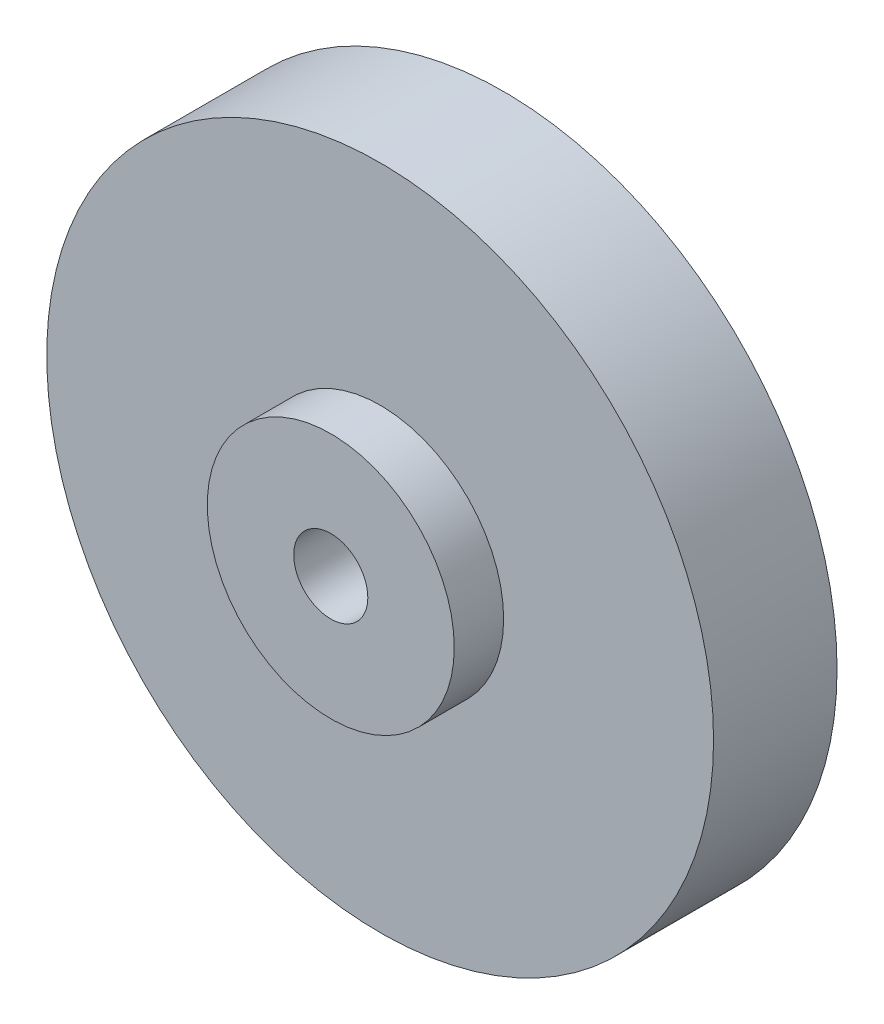
from build123d import *

# Parameters (mm, degrees)
SKETCH1_R           = 13.5
BOSS_EXTRUDE1_DEPTH = 5
SKETCH2_R           = 5
BOSS_EXTRUDE2_DEPTH = 2
SKETCH3_R           = 1.5
CUT_EXTRUDE1_DEPTH  = 8
CHAMFER1_SIZE       = 2


with BuildPart() as part:
    # Sketch1 → Boss-Extrude1 (new body)
    with BuildSketch(Plane.XY):
        Circle(SKETCH1_R)
    extrude(amount=BOSS_EXTRUDE1_DEPTH)

    # Sketch2 → Boss-Extrude2 (add)
    with BuildSketch(Plane.XY.offset(5)):
        Circle(SKETCH2_R)
    extrude(amount=BOSS_EXTRUDE2_DEPTH)

    # Sketch3 → Cut-Extrude1 (cut, through all)
    with BuildSketch(Plane.XY.offset(7)):
        Circle(SKETCH3_R)
    extrude(amount=-CUT_EXTRUDE1_DEPTH, mode=Mode.SUBTRACT)

    # Chamfer1
    chamfer1_edges = [part.edges().sort_by_distance(p)[0] for p in [
        (-1.5, 0, 0),
    ]]
    chamfer(chamfer1_edges, length=CHAMFER1_SIZE)


solid = part.part
